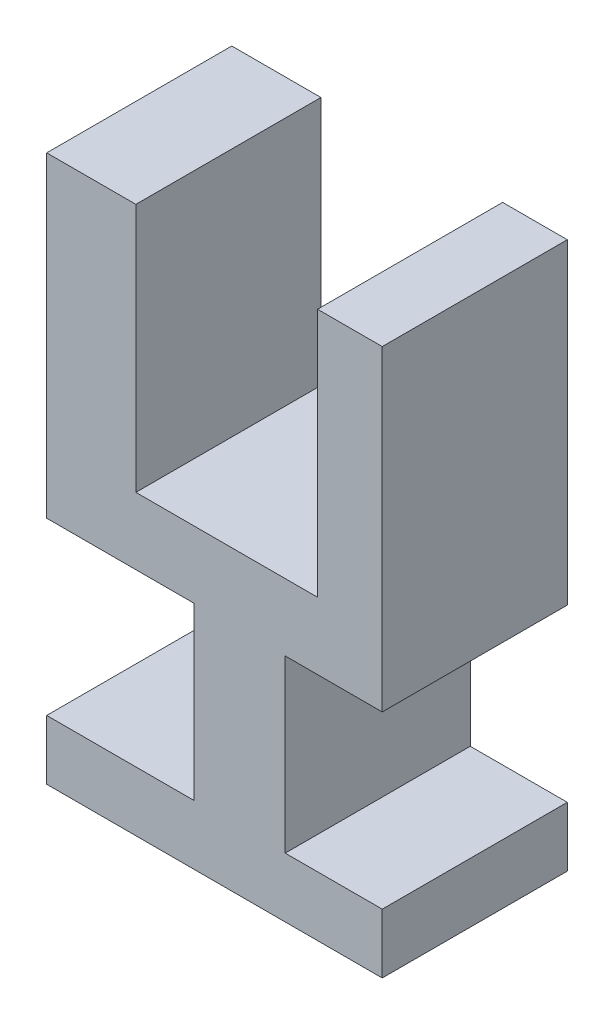
from build123d import *

# Parameters (mm, degrees)
BOSS_EXTRUDE1_DEPTH = 44


with BuildPart() as part:
    # Sketch1 → Boss-Extrude1 (new body)
    with BuildSketch(Plane.XY):
        Polygon((-51.984876267, 41.459769276), (-51.984876267, -17.846920549), (-8.78617627, -17.846920549), (-8.78617627, 41.459769276), (6.589632203, 41.459769276), (6.589632203, -33.771865039), (-16.478218796, -33.771865039), (-16.478218796, -74.374117789), (6.589632203, -74.374117789), (6.589632203, -88.550788925), (-73.184903339, -88.550788925), (-73.184903339, -74.374117789), (-38.215781204, -74.374117789), (-38.215781204, -33.771865039), (-73.184903339, -33.771865039), (-73.184903339, 41.459769276), align=None)
    extrude(amount=BOSS_EXTRUDE1_DEPTH)


solid = part.part
